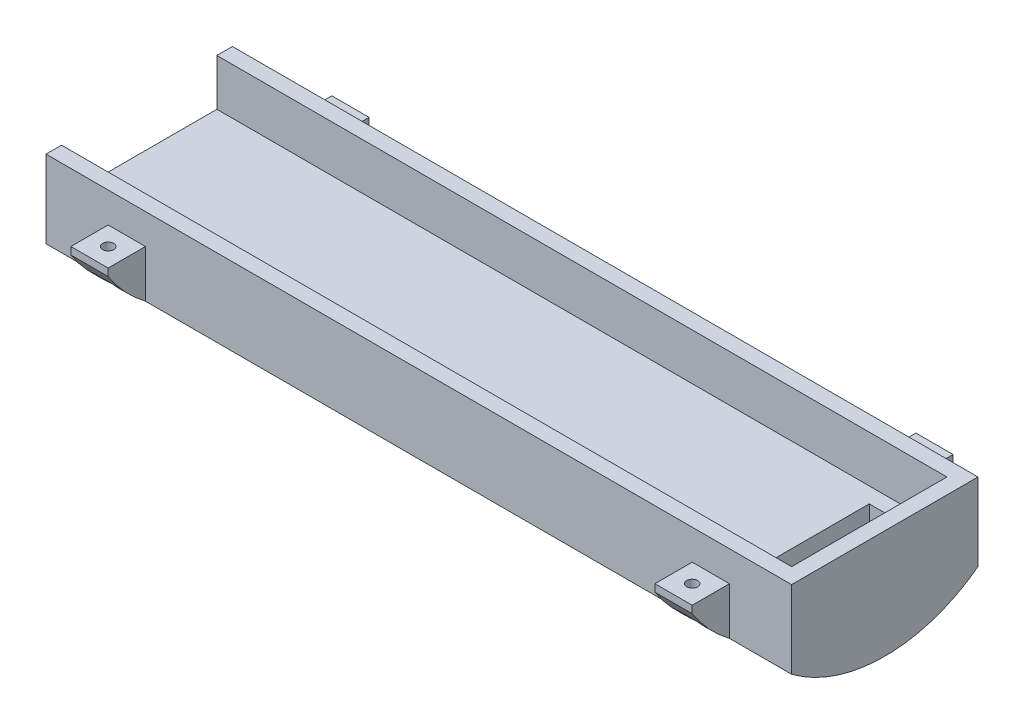
from build123d import *

# Parameters (mm, degrees)
SKETCH1_W                                   = 304.8
SKETCH1_H                                   = 76.2
BOSS_EXTRUDE1_DEPTH                         = 6.35
SKETCH3_W                                   = 25.4
SKETCH3_H                                   = 50.8
CUT_EXTRUDE2_DEPTH                          = 25.4
BOSS_EXTRUDE2_DEPTH                         = 19.05
BOSS_EXTRUDE3_DEPTH                         = 304.8
BOSS_EXTRUDE4_DEPTH                         = 15.24
BOSS_EXTRUDE5_DEPTH                         = 15.24
CBORE_FOR_8_BINDING_HEAD_MACHINE_SC_2_COUNT = 2
CBORE_FOR_8_BINDING_HEAD_MACHINE_SC_2_PITCH = 238.76
CBORE_FOR_8_BINDING_HEAD_MACHINE_SC_3_COUNT = 2
CBORE_FOR_8_BINDING_HEAD_MACHINE_SC_3_PITCH = 255.670904094
CBORE_FOR_8_BINDING_HEAD_MACHINE_SC_4_COUNT = 2
CBORE_FOR_8_BINDING_HEAD_MACHINE_SC_4_PITCH = 91.44
SKETCH12_R                                  = 2.2479
CUT_EXTRUDE3_DEPTH                          = 23.0345001


with BuildPart() as part:
    # Sketch1 → Boss-Extrude1 (new body)
    with BuildSketch(Plane(origin=(0, 0, 0), x_dir=(1, 0, 0), z_dir=(0, 1, 0))):
        Rectangle(SKETCH1_W, SKETCH1_H)
    extrude(amount=-BOSS_EXTRUDE1_DEPTH)

    # Sketch3 → Cut-Extrude2 (cut)
    with BuildSketch(Plane(origin=(0, 0, 0), x_dir=(1, 0, 0), z_dir=(0, 1, 0))):
        with Locations((133.35, 0)):
            Rectangle(SKETCH3_W, SKETCH3_H)
    extrude(amount=-CUT_EXTRUDE2_DEPTH, mode=Mode.SUBTRACT)

    # Sketch4 → Boss-Extrude2 (add)
    with BuildSketch(Plane(origin=(0, 0, 0), x_dir=(1, 0, 0), z_dir=(0, 1, 0))):
        Polygon((152.4, 38.1), (-152.4, 38.1), (-152.4, 31.75), (146.05, 31.75), (152.4, 31.75), align=None)
        Polygon((146.05, -31.75), (-152.4, -31.75), (-152.4, -38.1), (152.4, -38.1), (152.4, -31.75), align=None)
        Polygon((152.4, -31.75), (152.4, 31.75), (146.05, 31.75), (146.05, 25.4), (146.05, -25.4), (146.05, -31.75), align=None)
    extrude(amount=BOSS_EXTRUDE2_DEPTH)

    # Sketch5 → Boss-Extrude3 (add)
    with BuildSketch(Plane.ZY.offset(152.4)):
        with BuildLine():
            Line((38.1, -6.35), (-38.1, -6.35))
            Line((-38.1, -6.35), (-38.1, -12.7))
            ThreePointArc((-38.1, -12.7), (0, -25.4), (38.1, -12.7))
            Line((38.1, -12.7), (38.1, -6.35))
        make_face()
    extrude(amount=-BOSS_EXTRUDE3_DEPTH)

    # Sketch8 → Boss-Extrude4 (add)
    with BuildSketch(Plane.ZY.offset(127)):
        with BuildLine():
            Line((-38.1, -12.7), (-38.1, 6.6675))
            Line((-38.1, 6.6675), (-53.34, 6.6675))
            Line((-53.34, 6.6675), (-53.34, 3.645763686))
            ThreePointArc((-53.34, 3.645763686), (-46.444745641, -5.202835962), (-38.1, -12.7))
        make_face()
        with BuildLine():
            Line((53.34, 3.645763686), (53.34, 6.6675))
            Line((53.34, 6.6675), (38.1, 6.6675))
            Line((38.1, 6.6675), (38.1, -12.7))
            ThreePointArc((38.1, -12.7), (46.444745641, -5.202835962), (53.34, 3.645763686))
        make_face()
    extrude(amount=-BOSS_EXTRUDE4_DEPTH)

    # Sketch9 → Boss-Extrude5 (add)
    with BuildSketch(Plane.ZY.offset(-111.76)):
        with BuildLine():
            Line((-38.1, -12.7), (-38.1, 6.6675))
            Line((-38.1, 6.6675), (-53.34, 6.6675))
            Line((-53.34, 6.6675), (-53.34, 3.645763686))
            ThreePointArc((-53.34, 3.645763686), (-46.444745641, -5.202835962), (-38.1, -12.7))
        make_face()
        with BuildLine():
            Line((53.34, 3.645763686), (53.34, 6.6675))
            Line((53.34, 6.6675), (38.1, 6.6675))
            Line((38.1, 6.6675), (38.1, -12.7))
            ThreePointArc((38.1, -12.7), (46.444745641, -5.202835962), (53.34, 3.645763686))
        make_face()
    extrude(amount=-BOSS_EXTRUDE5_DEPTH)

    # Sketch11 → CBORE for #8 Binding Head Machine Screw1 (revolve, cut)
    with BuildSketch(Plane(origin=(-119.38, -6.0325, -45.72), x_dir=(0, 0, -1), z_dir=(1, 0, 0))):
        Polygon((0, 0), (0, 25.0825), (2.2479, 25.0825), (2.2479, 2.667), (4.7625, 2.667), (4.7625, 0), align=None)
    cbore_for_8_binding_head_machine_screw1 = revolve(axis=Axis((-119.38, -12.3825, -45.72), (0, 1, 0)), mode=Mode.SUBTRACT)

    # CBORE for _8 Binding Head Machine Sc 2: CBORE for #8 Binding Head Machine Screw1 ×2
    with Locations(*[(i * CBORE_FOR_8_BINDING_HEAD_MACHINE_SC_2_PITCH, 0, 0) for i in range(1, CBORE_FOR_8_BINDING_HEAD_MACHINE_SC_2_COUNT)]):
        add(cbore_for_8_binding_head_machine_screw1, mode=Mode.SUBTRACT)

    # CBORE for _8 Binding Head Machine Sc 3: CBORE for #8 Binding Head Machine Screw1 ×2
    with Locations(*[Vector(0.933856752, 0, 0.357647267) * (i * CBORE_FOR_8_BINDING_HEAD_MACHINE_SC_3_PITCH) for i in range(1, CBORE_FOR_8_BINDING_HEAD_MACHINE_SC_3_COUNT)]):
        add(cbore_for_8_binding_head_machine_screw1, mode=Mode.SUBTRACT)

    # CBORE for _8 Binding Head Machine Sc 4: CBORE for #8 Binding Head Machine Screw1 ×2
    with Locations(*[(0, 0, i * CBORE_FOR_8_BINDING_HEAD_MACHINE_SC_4_PITCH) for i in range(1, CBORE_FOR_8_BINDING_HEAD_MACHINE_SC_4_COUNT)]):
        add(cbore_for_8_binding_head_machine_screw1, mode=Mode.SUBTRACT)

    # Sketch12 → Cut-Extrude3 (cut, through all)
    with BuildSketch(Plane.XZ.offset(3.3655)):
        with BuildLine():
            Line((-123.509642203, -48.092227124), (-115.250357797, -48.092227124))
            ThreePointArc((-115.250357797, -48.092227124), (-119.38, -40.9575), (-123.509642203, -48.092227124))
        make_face()
        with BuildLine():
            ThreePointArc((-114.6175, -45.72), (-120.607596281, -41.118433569), (-123.509642203, -48.092227124))
            Line((-123.509642203, -48.092227124), (-115.250357797, -48.092227124))
            ThreePointArc((-115.250357797, -48.092227124), (-114.778433569, -46.947596281), (-114.6175, -45.72))
        make_face()
        with BuildLine():
            Line((-115.250357797, -48.092227124), (-123.509642203, -48.092227124))
            ThreePointArc((-123.509642203, -48.092227124), (-119.38, -50.4825), (-115.250357797, -48.092227124))
        make_face()
        with BuildLine():
            Line((-123.509642203, 48.092227124), (-115.250357797, 48.092227124))
            ThreePointArc((-115.250357797, 48.092227124), (-119.38, 50.4825), (-123.509642203, 48.092227124))
        make_face()
        with BuildLine():
            ThreePointArc((-123.509642203, 48.092227124), (-119.38, 40.9575), (-115.250357797, 48.092227124))
            Line((-115.250357797, 48.092227124), (-123.509642203, 48.092227124))
        make_face()
        with Locations((-119.38, 45.72)):
            Circle(SKETCH12_R, mode=Mode.SUBTRACT)
        with BuildLine():
            ThreePointArc((124.1425, 45.72), (123.981566431, 46.947596281), (123.509642203, 48.092227124))
            Line((123.509642203, 48.092227124), (115.250357797, 48.092227124))
            ThreePointArc((115.250357797, 48.092227124), (118.152403719, 41.118433569), (124.1425, 45.72))
        make_face()
        with BuildLine():
            Line((115.250357797, 48.092227124), (123.509642203, 48.092227124))
            ThreePointArc((123.509642203, 48.092227124), (119.38, 50.4825), (115.250357797, 48.092227124))
        make_face()
        with BuildLine():
            Line((123.509642203, 48.092227124), (115.250357797, 48.092227124))
            ThreePointArc((115.250357797, 48.092227124), (119.38, 40.9575), (123.509642203, 48.092227124))
        make_face()
        with BuildLine():
            Line((115.250357797, -48.092227124), (123.509642203, -48.092227124))
            ThreePointArc((123.509642203, -48.092227124), (119.38, -40.9575), (115.250357797, -48.092227124))
        make_face()
        with BuildLine():
            ThreePointArc((124.1425, -45.72), (118.152403719, -41.118433569), (115.250357797, -48.092227124))
            Line((115.250357797, -48.092227124), (123.509642203, -48.092227124))
            ThreePointArc((123.509642203, -48.092227124), (123.981566431, -46.947596281), (124.1425, -45.72))
        make_face()
        with BuildLine():
            Line((123.509642203, -48.092227124), (115.250357797, -48.092227124))
            ThreePointArc((115.250357797, -48.092227124), (119.38, -50.4825), (123.509642203, -48.092227124))
        make_face()
        with Locations((-119.38, 45.72)):
            Circle(SKETCH12_R)
    extrude(amount=CUT_EXTRUDE3_DEPTH, mode=Mode.SUBTRACT)


solid = part.part
